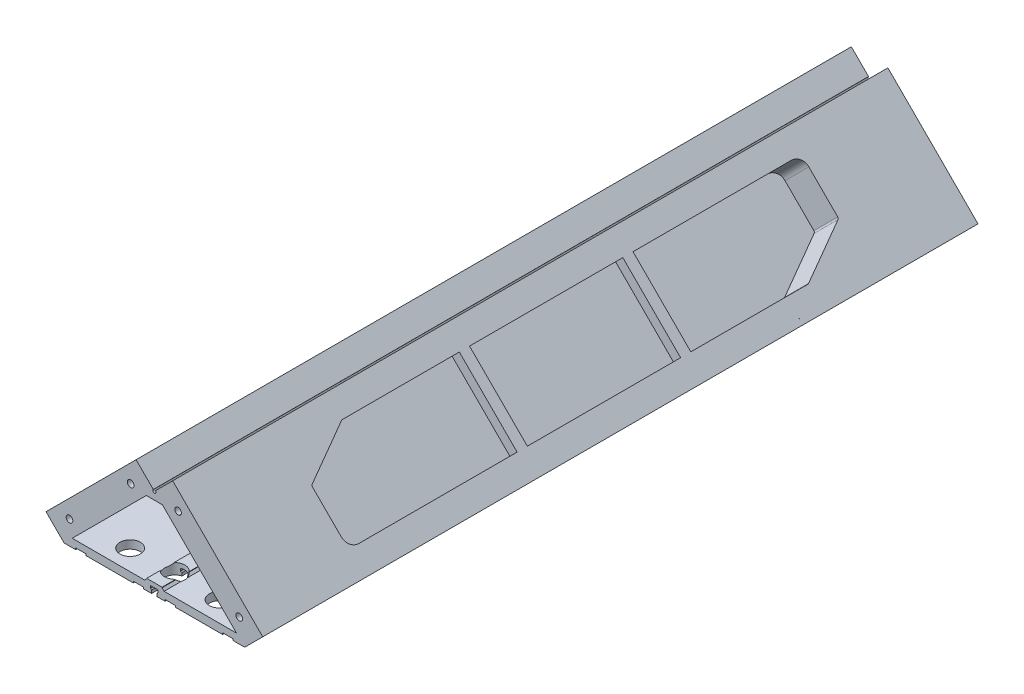
from build123d import *

# Parameters (mm, degrees)
SKETCH1_W            = 540
SKETCH1_H            = 840
BOSS_EXTRUDE1_DEPTH  = 25
SKETCH2_W            = 25
SKETCH2_H            = 25
SKETCH2_W_2          = 21
SKETCH2_H_2          = 21
BOSS_EXTRUDE2_DEPTH  = 700
SKETCH4_W            = 540
SKETCH4_H            = 840
BOSS_EXTRUDE3_DEPTH  = 25
SKETCH6_W            = 4
SKETCH6_H            = 20
BOSS_EXTRUDE4_DEPTH  = 25
SKETCH8_W            = 4
SKETCH8_H            = 20
BOSS_EXTRUDE5_DEPTH  = 25
BOSS_EXTRUDE6_DEPTH  = 750
SKETCH10_R           = 20
BOSS_EXTRUDE7_DEPTH  = 6
SKETCH11_W           = 28
SKETCH11_H           = 45
BOSS_EXTRUDE8_DEPTH  = 2
SKETCH12_W           = 2
SKETCH12_H           = 45
BOSS_EXTRUDE9_DEPTH  = 38
CUT_EXTRUDE1_DEPTH   = 633.198416853
FILLET1_R            = 6
SKETCH14_R           = 25
BOSS_EXTRUDE10_DEPTH = 24
SKETCH15_R           = 25
BOSS_EXTRUDE11_DEPTH = 24
BOSS_EXTRUDE13_DEPTH = 700
SKETCH19_OUTSIDE_W   = 1016.89
SKETCH19_OUTSIDE_H   = 1690.493
CUT_EXTRUDE2_DEPTH   = 789.020646546
SKETCH20_R           = 150.366879017
CUT_EXTRUDE3_DEPTH   = 25
SKETCH21_R           = 126.600739992
CUT_EXTRUDE4_DEPTH   = 25
SKETCH22_R           = 452.219226755
CUT_EXTRUDE5_DEPTH   = 39.020646546
SKETCH25_W           = 10.2
SKETCH25_H           = 3
CUT_EXTRUDE7_DEPTH   = 701
CUT_EXTRUDE8_DEPTH   = 701
SKETCH32_W           = 15
SKETCH32_H           = 2.5
BOSS_EXTRUDE15_DEPTH = 700
CHAMFER1_SIZE        = 2
CHAMFER2_SIZE        = 2
BOSS_EXTRUDE16_DEPTH = 700
CUT_EXTRUDE12_DEPTH  = 6
BOSS_EXTRUDE17_DEPTH = 33
BOSS_EXTRUDE18_DEPTH = 4
FILLET2_R            = 2
CUT_EXTRUDE13_DEPTH  = 10
BOSS_EXTRUDE19_DEPTH = 33
BOSS_EXTRUDE20_DEPTH = 4
BOSS_EXTRUDE21_DEPTH = 10
BOSS_EXTRUDE22_DEPTH = 10
SKETCH48_R           = 10
CUT_EXTRUDE14_DEPTH  = 20
SKETCH49_W           = 350
SKETCH49_H           = 5
CUT_EXTRUDE15_DEPTH  = 10
FILLET3_R            = 2
SKETCH50_W           = 350
SKETCH50_H           = 5
CUT_EXTRUDE16_DEPTH  = 10
FILLET4_R            = 2
SKETCH51_W           = 10
SKETCH51_H           = 80
BOSS_EXTRUDE23_DEPTH = 10
SKETCH53_W           = 10
SKETCH53_H           = 80
BOSS_EXTRUDE24_DEPTH = 10
BOSS_EXTRUDE25_DEPTH = 15
BOSS_EXTRUDE26_DEPTH = 15
SKETCH57_R           = 3.25
CUT_EXTRUDE17_DEPTH  = 20
SKETCH58_R           = 3.25
CUT_EXTRUDE18_DEPTH  = 20


with BuildPart() as part:
    # Sketch1 → Boss-Extrude1 (new body)
    with BuildSketch(Plane.XY):
        Polygon((565, 0), (590, 0), (590, 950), (613.198051534, 926.801948466), (630.875721064, 944.479617996), (312.67766953, 1262.67766953), (295, 1280.355339059), (277.32233047, 1262.67766953), (-40.875721064, 944.479617996), (-23.198051534, 926.801948466), (0, 950), (0, 0), (25, 0), (25, 30), (565, 30), align=None)
        with Locations((295, 475)):
            Rectangle(SKETCH1_W, SKETCH1_H, mode=Mode.SUBTRACT)
        Polygon((25, 920), (565, 920), (565, 950), (565, 975), (295, 1245), (25, 975), (25, 950), align=None, mode=Mode.SUBTRACT)
    extrude(amount=BOSS_EXTRUDE1_DEPTH)

    # Sketch2 → Boss-Extrude2 (add)
    with BuildSketch(Plane.XY.offset(25)):
        with Locations((12.5, 42.5)):
            Rectangle(SKETCH2_W, SKETCH2_H)
        with Locations((12.5, 42.5)):
            Rectangle(SKETCH2_W_2, SKETCH2_H_2, mode=Mode.SUBTRACT)
        with Locations((577.5, 42.5)):
            Rectangle(SKETCH2_W, SKETCH2_H)
        with Locations((577.5, 42.5)):
            Rectangle(SKETCH2_W_2, SKETCH2_H_2, mode=Mode.SUBTRACT)
        Polygon((295, 1280.355339059), (312.67766953, 1262.67766953), (295, 1245), (277.32233047, 1262.67766953), align=None)
        Polygon((295, 1277.526911935), (309.849242405, 1262.67766953), (295, 1247.828427125), (280.150757595, 1262.67766953), align=None, mode=Mode.SUBTRACT)
        with Locations((12.5, 907.5)):
            Rectangle(SKETCH2_W, SKETCH2_H)
        with Locations((12.5, 907.5)):
            Rectangle(SKETCH2_W_2, SKETCH2_H_2, mode=Mode.SUBTRACT)
        with Locations((577.5, 907.5)):
            Rectangle(SKETCH2_W, SKETCH2_H)
        with Locations((577.5, 907.5)):
            Rectangle(SKETCH2_W_2, SKETCH2_H_2, mode=Mode.SUBTRACT)
    extrude(amount=BOSS_EXTRUDE2_DEPTH)

    # Sketch4 → Boss-Extrude3 (add)
    with BuildSketch(Plane.XY.offset(725)):
        Polygon((590, 895), (590, 920), (590, 950), (613.198051534, 926.801948466), (630.875721064, 944.479617996), (312.67766953, 1262.67766953), (295, 1280.355339059), (277.32233047, 1262.67766953), (-40.875721064, 944.479617996), (-23.198051534, 926.801948466), (0, 950), (0, 920), (0, 895), (0, 55), (0, 30), (0, 0), (25, 0), (25, 30), (565, 30), (565, 0), (590, 0), (590, 30), (590, 55), align=None)
        with Locations((295, 475)):
            Rectangle(SKETCH4_W, SKETCH4_H, mode=Mode.SUBTRACT)
        Polygon((565, 920), (25, 920), (25, 975), (295, 1245), (565, 975), align=None, mode=Mode.SUBTRACT)
    extrude(amount=BOSS_EXTRUDE3_DEPTH)

    # Sketch6 → Boss-Extrude4 (add)
    with BuildSketch(Plane(origin=(0, 0, 0), x_dir=(-1, 0, 0), z_dir=(0, 0, -1))):
        with Locations((-27, 265)):
            Rectangle(SKETCH6_W, SKETCH6_H)
        with Locations((-27, 665)):
            Rectangle(SKETCH6_W, SKETCH6_H)
        with Locations((-563, 665)):
            Rectangle(SKETCH6_W, SKETCH6_H)
        with Locations((-563, 265)):
            Rectangle(SKETCH6_W, SKETCH6_H)
    extrude(amount=-BOSS_EXTRUDE4_DEPTH)

    # Sketch8 → Boss-Extrude5 (add)
    with BuildSketch(Plane.XY.offset(750)):
        with Locations((27, 665)):
            Rectangle(SKETCH8_W, SKETCH8_H)
        with Locations((27, 265)):
            Rectangle(SKETCH8_W, SKETCH8_H)
        with Locations((563, 265)):
            Rectangle(SKETCH8_W, SKETCH8_H)
        with Locations((563, 665)):
            Rectangle(SKETCH8_W, SKETCH8_H)
    extrude(amount=-BOSS_EXTRUDE5_DEPTH)

    # Sketch9 → Boss-Extrude6 (add)
    with BuildSketch(Plane.XY.offset(750)):
        Polygon((561, 255), (551, 255), (551, 257), (559, 257), (559, 270), (561, 270), align=None)
        Polygon((561, 655), (551, 655), (551, 657), (559, 657), (559, 670), (561, 670), align=None)
        Polygon((31, 670), (31, 657), (39, 657), (39, 655), (29, 655), (29, 670), align=None)
        Polygon((31, 270), (31, 257), (39, 257), (39, 255), (29, 255), (29, 270), align=None)
    extrude(amount=-BOSS_EXTRUDE6_DEPTH)

    # Sketch10 → Boss-Extrude7 (add)
    with BuildSketch(Plane.XZ):
        with Locations((577.5, 12.5)):
            Circle(SKETCH10_R)
        with Locations((577.5, 737.5)):
            Circle(SKETCH10_R)
        with Locations((12.5, 737.5)):
            Circle(SKETCH10_R)
        with Locations((12.5, 12.5)):
            Circle(SKETCH10_R)
    extrude(amount=BOSS_EXTRUDE7_DEPTH)

    # Sketch11 → Boss-Extrude8 (add)
    with BuildSketch(Plane.XZ.offset(6)):
        with Locations((577.32269579, 3.479353454)):
            Rectangle(SKETCH11_W, SKETCH11_H)
        with Locations((577.32269579, 746.520646546)):
            Rectangle(SKETCH11_W, SKETCH11_H)
        with Locations((12.67730421, 746.520646546)):
            Rectangle(SKETCH11_W, SKETCH11_H)
        with Locations((12.67730421, 3.479353454)):
            Rectangle(SKETCH11_W, SKETCH11_H)
    extrude(amount=BOSS_EXTRUDE8_DEPTH)

    # Sketch12 → Boss-Extrude9 (add)
    with BuildSketch(Plane.XZ.offset(8)):
        with Locations((590.32269579, 3.479353454)):
            Rectangle(SKETCH12_W, SKETCH12_H)
        with Locations((564.32269579, 3.479353454)):
            Rectangle(SKETCH12_W, SKETCH12_H)
        with Locations((25.67730421, 3.479353454)):
            Rectangle(SKETCH12_W, SKETCH12_H)
        with Locations((-0.32269579, 3.479353454)):
            Rectangle(SKETCH12_W, SKETCH12_H)
        with Locations((-0.32269579, 746.520646546)):
            Rectangle(SKETCH12_W, SKETCH12_H)
        with Locations((25.67730421, 746.520646546)):
            Rectangle(SKETCH12_W, SKETCH12_H)
        with Locations((564.32269579, 746.520646546)):
            Rectangle(SKETCH12_W, SKETCH12_H)
        with Locations((590.32269579, 746.520646546)):
            Rectangle(SKETCH12_W, SKETCH12_H)
    extrude(amount=BOSS_EXTRUDE9_DEPTH)

    # Sketch13 → Cut-Extrude1 (cut, through all)
    with BuildSketch(Plane(origin=(591.32269579, 0, 0), x_dir=(0, 0, -1), z_dir=(1, 0, 0))):
        Polygon((-25.979353454, -6), (9.020646546, -46), (-32.88674387, -57.116728835), align=None)
        Polygon((-717.11325613, -57.116728835), (-724.020646546, -6), (-759.020646546, -46), align=None)
    extrude(amount=-CUT_EXTRUDE1_DEPTH, mode=Mode.SUBTRACT)

    # Fillet1
    fillet1_edges = [part.edges().sort_by_distance(p)[0] for p in [
        (590.32269579, -46, -19.020646546),
        (564.32269579, -46, -19.020646546),
        (25.67730421, -46, -19.020646546),
        (-0.32269579, -46, -19.020646546),
        (-0.32269579, -46, 769.020646546),
        (25.67730421, -46, 769.020646546),
        (564.32269579, -46, 769.020646546),
        (590.32269579, -46, 769.020646546),
        (590.32269579, -46, 759.020646546),
        (-0.32269579, -46, -9.020646546),
        (25.67730421, -46, -9.020646546),
        (564.32269579, -46, -9.020646546),
        (590.32269579, -46, -9.020646546),
        (564.32269579, -46, 759.020646546),
        (-0.32269579, -46, 759.020646546),
        (25.67730421, -46, 759.020646546),
    ]]
    fillet(fillet1_edges, radius=FILLET1_R)

    # Sketch14 → Boss-Extrude10 (add)
    with BuildSketch(Plane(origin=(565.32269579, 0, 0), x_dir=(0, 0, -1), z_dir=(1, 0, 0))):
        with Locations((13.020646546, -40)):
            Circle(SKETCH14_R)
        with Locations((-763.020646546, -40)):
            Circle(SKETCH14_R)
    extrude(amount=BOSS_EXTRUDE10_DEPTH)

    # Sketch15 → Boss-Extrude11 (add)
    with BuildSketch(Plane.ZY.offset(-24.67730421)):
        with Locations((763.020646546, -40)):
            Circle(SKETCH15_R)
        with Locations((-13.020646546, -40)):
            Circle(SKETCH15_R)
    extrude(amount=BOSS_EXTRUDE11_DEPTH)

    # Sketch18 → Boss-Extrude13 (add)
    with BuildSketch(Plane.XY.offset(25)):
        with BuildLine():
            Line((277.110198436, 1262.465537495), (188.933982822, 1174.289321881))
            Line((188.933982822, 1174.289321881), (206.611652352, 1156.611652352))
            Line((206.611652352, 1156.611652352), (383.388347648, 1156.611652352))
            Line((383.388347648, 1156.611652352), (401.066017178, 1174.289321881))
            Line((401.066017178, 1174.289321881), (312.889801564, 1262.465537495))
            Line((312.889801564, 1262.465537495), (296.060660172, 1245.636396103))
            ThreePointArc((296.060660172, 1245.636396103), (295, 1243.075735931), (293.939339828, 1245.636396103))
            Line((293.939339828, 1245.636396103), (277.110198436, 1262.465537495))
        make_face()
        Polygon((277.110198436, 1255.394469683), (196.005050634, 1174.289321881), (205.682720164, 1164.611652352), (384.317279836, 1164.611652352), (393.994949366, 1174.289321881), (312.889801564, 1255.394469683), (295, 1237.504668119), align=None, mode=Mode.SUBTRACT)
    extrude(amount=BOSS_EXTRUDE13_DEPTH)

    # Sketch19 outside → Cut-Extrude2 (cut, through all)
    with BuildSketch(Plane(origin=(0, 0, 0), x_dir=(-1, 0, 0), z_dir=(0, 0, -1))):
        with Locations((-295, 607.6775)):
            Rectangle(SKETCH19_OUTSIDE_W, SKETCH19_OUTSIDE_H)
        with BuildLine():
            Line((-401.066017178, 1174.289321881), (-312.889801564, 1262.465537495))
            Line((-312.889801564, 1262.465537495), (-296.060660172, 1245.636396103))
            ThreePointArc((-296.060660172, 1245.636396103), (-295, 1243.075735931), (-293.939339828, 1245.636396103))
            Line((-293.939339828, 1245.636396103), (-277.110198436, 1262.465537495))
            Line((-277.110198436, 1262.465537495), (-188.933982822, 1174.289321881))
            Line((-188.933982822, 1174.289321881), (-206.611652352, 1156.611652352))
            Line((-206.611652352, 1156.611652352), (-383.388347648, 1156.611652352))
            Line((-383.388347648, 1156.611652352), (-401.066017178, 1174.289321881))
        make_face(mode=Mode.SUBTRACT)
    extrude(amount=-CUT_EXTRUDE2_DEPTH, mode=Mode.SUBTRACT)

    # Sketch20 → Cut-Extrude3 (cut)
    with BuildSketch(Plane(origin=(0, 0, 0), x_dir=(-1, 0, 0), z_dir=(0, 0, -1))):
        with Locations((-293.022121053, 1200.600764851)):
            Circle(SKETCH20_R)
    extrude(amount=-CUT_EXTRUDE3_DEPTH, mode=Mode.SUBTRACT)

    # Sketch21 → Cut-Extrude4 (cut)
    with BuildSketch(Plane.XY.offset(750)):
        with Locations((288.084440034, 1190.288136264)):
            Circle(SKETCH21_R)
    extrude(amount=-CUT_EXTRUDE4_DEPTH, mode=Mode.SUBTRACT)

    # Sketch22 → Cut-Extrude5 (cut, through all)
    with BuildSketch(Plane.XY):
        with Locations((322.401617547, 0)):
            Circle(SKETCH22_R)
    extrude(amount=-CUT_EXTRUDE5_DEPTH, mode=Mode.SUBTRACT)

    # Sketch25 → Cut-Extrude7 (cut, through all)
    with BuildSketch(Plane(origin=(0, 0, 25), x_dir=(-1, 0, 0), z_dir=(0, 0, -1))):
        with Locations((-366.883174851, 1156.611652352)):
            Rectangle(SKETCH25_W, SKETCH25_H)
        with Locations((-310.559598677, 1156.611652352)):
            Rectangle(SKETCH25_W, SKETCH25_H)
        with Locations((-279.440401323, 1156.611652352)):
            Rectangle(SKETCH25_W, SKETCH25_H)
        with Locations((-223.116825149, 1156.611652352)):
            Rectangle(SKETCH25_W, SKETCH25_H)
    extrude(amount=-CUT_EXTRUDE7_DEPTH, mode=Mode.SUBTRACT)

    # Sketch28 → Cut-Extrude8 (cut, through all)
    with BuildSketch(Plane(origin=(0, 0, 25), x_dir=(-1, 0, 0), z_dir=(0, 0, -1))):
        Polygon((-297.7, 1153.411652352), (-292.3, 1153.411652352), (-292.3, 1159.528809639), (-291.3, 1160.528809639), (-291.3, 1162.811652352), (-298.7, 1162.811652352), (-298.7, 1160.528809639), (-297.7, 1159.528809639), align=None)
    extrude(amount=-CUT_EXTRUDE8_DEPTH, mode=Mode.SUBTRACT)

    # Sketch32 → Boss-Extrude15 (add)
    with BuildSketch(Plane(origin=(0, 0, 25), x_dir=(-1, 0, 0), z_dir=(0, 0, -1))):
        with Locations((-295, 1165.861652352)):
            Rectangle(SKETCH32_W, SKETCH32_H)
    extrude(amount=-BOSS_EXTRUDE15_DEPTH)

    # Chamfer1
    chamfer1_edges = [part.edges().sort_by_distance(p)[0] for p in [
        (302.5, 1164.611652352, 375),
    ]]
    chamfer(chamfer1_edges, length=CHAMFER1_SIZE)

    # Chamfer2
    chamfer2_edges = [part.edges().sort_by_distance(p)[0] for p in [
        (287.5, 1164.611652352, 375),
    ]]
    chamfer(chamfer2_edges, length=CHAMFER2_SIZE)

    # Sketch36 → Boss-Extrude16 (add)
    with BuildSketch(Plane(origin=(0, 0, 25), x_dir=(-1, 0, 0), z_dir=(0, 0, -1))):
        with BuildLine():
            Line((-291.204031039, 1245.108659773), (-287.5, 1245.108659773))
            Line((-287.5, 1245.108659773), (-287.5, 1237.108659773))
            Line((-287.5, 1237.108659773), (-302.5, 1237.108659773))
            Line((-302.5, 1237.108659773), (-302.5, 1245.108659773))
            Line((-302.5, 1245.108659773), (-298.795968961, 1245.108659773))
            ThreePointArc((-298.795968961, 1245.108659773), (-295, 1240.742540375), (-291.204031039, 1245.108659773))
        make_face()
    extrude(amount=-BOSS_EXTRUDE16_DEPTH)

    # Sketch38 → Cut-Extrude12 (cut)
    with BuildSketch(Plane(origin=(787.67766953, 787.67766953, 0), x_dir=(0, 0, -1), z_dir=(0.707106781, 0.707106781, 0))):
        with BuildLine():
            Line((-575, 649.451442127), (-135, 649.451442127))
            ThreePointArc((-135, 649.451442127), (-127.928932188, 646.522509939), (-125, 639.451442127))
            Line((-125, 639.451442127), (-125, 598.318955587))
            Line((-125, 598.318955587), (-175, 569.451442127))
            Line((-175, 569.451442127), (-615, 569.451442127))
            ThreePointArc((-615, 569.451442127), (-622.071067812, 572.380374315), (-625, 579.451442127))
            Line((-625, 579.451442127), (-625, 620.583928668))
            Line((-625, 620.583928668), (-575, 649.451442127))
        make_face()
    extrude(amount=-CUT_EXTRUDE12_DEPTH, mode=Mode.SUBTRACT)

    # Sketch39 → Boss-Extrude17 (add)
    with BuildSketch(Plane(origin=(787.67766953, 787.67766953, 0), x_dir=(0, 0, -1), z_dir=(0.707106781, 0.707106781, 0))):
        with BuildLine():
            Line((-121, 596.00955451), (-121, 639.451442127))
            ThreePointArc((-121, 639.451442127), (-125.100505063, 649.350937064), (-135, 653.451442127))
            Line((-135, 653.451442127), (-576.07179677, 653.451442127))
            Line((-576.07179677, 653.451442127), (-629, 622.893329745))
            Line((-629, 622.893329745), (-629, 579.451442127))
            ThreePointArc((-629, 579.451442127), (-624.899494937, 569.551947191), (-615, 565.451442127))
            Line((-615, 565.451442127), (-173.92820323, 565.451442127))
            Line((-173.92820323, 565.451442127), (-121, 596.00955451))
        make_face()
        with BuildLine():
            Line((-125, 598.318955587), (-125, 639.451442127))
            ThreePointArc((-125, 639.451442127), (-127.928932188, 646.522509939), (-135, 649.451442127))
            Line((-135, 649.451442127), (-575, 649.451442127))
            Line((-575, 649.451442127), (-625, 620.583928668))
            Line((-625, 620.583928668), (-625, 579.451442127))
            ThreePointArc((-625, 579.451442127), (-622.071067812, 572.380374315), (-615, 569.451442127))
            Line((-615, 569.451442127), (-175, 569.451442127))
            Line((-175, 569.451442127), (-125, 598.318955587))
        make_face(mode=Mode.SUBTRACT)
    extrude(amount=-BOSS_EXTRUDE17_DEPTH)

    # Sketch40 → Boss-Extrude18 (add)
    with BuildSketch(Plane(origin=(764.343145751, 764.34314575, 0), x_dir=(0, 0, 1), z_dir=(-0.707106781, -0.707106781, 0))):
        with BuildLine():
            Line((172.865228929, 566.065150626), (619.099658504, 566.065150626))
            ThreePointArc((619.099658504, 566.065150626), (626.256003266, 571.126636395), (629, 579.451442127))
            Line((629, 579.451442127), (629, 622.893329745))
            Line((629, 622.893329745), (576.07179677, 653.451442127))
            Line((576.07179677, 653.451442127), (135, 653.451442127))
            ThreePointArc((135, 653.451442127), (125.100505063, 649.350937064), (121, 639.451442127))
            Line((121, 639.451442127), (121, 596.00955451))
            Line((121, 596.00955451), (172.865228929, 566.065150626))
        make_face()
    extrude(amount=BOSS_EXTRUDE18_DEPTH)

    # Fillet2
    fillet2_edges = [part.edges().sort_by_distance(p)[0] for p in [
        (352.935016832, 1199.085798448, 125),
        (373.347431355, 1178.673383925, 175),
        (337.191303384, 1214.829511896, 625),
        (316.778888861, 1235.24192642, 575),
    ]]
    fillet(fillet2_edges, radius=FILLET2_R)

    # Sketch42 → Cut-Extrude13 (cut)
    with BuildSketch(Plane(origin=(-492.67766953, 492.67766953, 0), x_dir=(0, 0, 1), z_dir=(-0.707106781, 0.707106781, 0))):
        with BuildLine():
            Line((175, 1066.644443027), (615, 1066.644443027))
            ThreePointArc((615, 1066.644443027), (622.071067812, 1063.715510839), (625, 1056.644443027))
            Line((625, 1056.644443027), (625, 1015.511956487))
            Line((625, 1015.511956487), (575, 986.644443027))
            Line((575, 986.644443027), (135, 986.644443027))
            ThreePointArc((135, 986.644443027), (127.928932188, 989.573375215), (125, 996.644443027))
            Line((125, 996.644443027), (125, 1037.776929568))
            Line((125, 1037.776929568), (175, 1066.644443027))
        make_face()
    extrude(amount=-CUT_EXTRUDE13_DEPTH, mode=Mode.SUBTRACT)

    # Sketch43 → Boss-Extrude19 (add)
    with BuildSketch(Plane(origin=(-492.67766953, 492.67766953, 0), x_dir=(0, 0, 1), z_dir=(-0.707106781, 0.707106781, 0))):
        with BuildLine():
            Line((615, 1070.644443027), (173.92820323, 1070.644443027))
            Line((173.92820323, 1070.644443027), (121, 1040.086330645))
            Line((121, 1040.086330645), (121, 996.644443027))
            ThreePointArc((121, 996.644443027), (125.100505063, 986.744948091), (135, 982.644443027))
            Line((135, 982.644443027), (576.07179677, 982.644443027))
            Line((576.07179677, 982.644443027), (629, 1013.20255541))
            Line((629, 1013.20255541), (629, 1056.644443027))
            ThreePointArc((629, 1056.644443027), (624.899494937, 1066.543937964), (615, 1070.644443027))
        make_face()
        with BuildLine():
            Line((615, 1066.644443027), (175, 1066.644443027))
            Line((175, 1066.644443027), (125, 1037.776929568))
            Line((125, 1037.776929568), (125, 996.644443027))
            ThreePointArc((125, 996.644443027), (127.928932188, 989.573375215), (135, 986.644443027))
            Line((135, 986.644443027), (575, 986.644443027))
            Line((575, 986.644443027), (625, 1015.511956487))
            Line((625, 1015.511956487), (625, 1056.644443027))
            ThreePointArc((625, 1056.644443027), (622.071067812, 1063.715510839), (615, 1066.644443027))
        make_face(mode=Mode.SUBTRACT)
    extrude(amount=-BOSS_EXTRUDE19_DEPTH)

    # Sketch44 → Boss-Extrude20 (add)
    with BuildSketch(Plane(origin=(-469.343145751, 469.343145751, 0), x_dir=(0, 0, -1), z_dir=(0.707106781, -0.707106781, 0))):
        with BuildLine():
            Line((-577.134771071, 983.258151526), (-130.900341496, 983.258151526))
            ThreePointArc((-130.900341496, 983.258151526), (-123.743996734, 988.319637296), (-121, 996.644443027))
            Line((-121, 996.644443027), (-121, 1040.086330645))
            Line((-121, 1040.086330645), (-173.92820323, 1070.644443027))
            Line((-173.92820323, 1070.644443027), (-615, 1070.644443027))
            ThreePointArc((-615, 1070.644443027), (-624.899494937, 1066.543937964), (-629, 1056.644443027))
            Line((-629, 1056.644443027), (-629, 1013.20255541))
            Line((-629, 1013.20255541), (-577.134771071, 983.258151526))
        make_face()
    extrude(amount=BOSS_EXTRUDE20_DEPTH)

    # Sketch46 → Boss-Extrude21 (add)
    with BuildSketch(Plane(origin=(787.67766953, 787.67766953, 0), x_dir=(0, 0, -1), z_dir=(0.707106781, 0.707106781, 0))):
        with BuildLine():
            Line((-135, 659.451442127), (-577.679491924, 659.451442127))
            Line((-577.679491924, 659.451442127), (-635, 626.35743136))
            Line((-635, 626.35743136), (-635, 579.451442127))
            ThreePointArc((-635, 579.451442127), (-629.142135624, 565.309306503), (-615, 559.451442127))
            Line((-615, 559.451442127), (-172.320508076, 559.451442127))
            Line((-172.320508076, 559.451442127), (-115, 592.545452895))
            Line((-115, 592.545452895), (-115, 639.451442127))
            ThreePointArc((-115, 639.451442127), (-120.857864376, 653.593577751), (-135, 659.451442127))
        make_face()
        with BuildLine():
            Line((-135, 649.451442127), (-575, 649.451442127))
            Line((-575, 649.451442127), (-625, 620.583928668))
            Line((-625, 620.583928668), (-625, 579.451442127))
            ThreePointArc((-625, 579.451442127), (-622.071067812, 572.380374315), (-615, 569.451442127))
            Line((-615, 569.451442127), (-175, 569.451442127))
            Line((-175, 569.451442127), (-125, 598.318955587))
            Line((-125, 598.318955587), (-125, 639.451442127))
            ThreePointArc((-125, 639.451442127), (-127.928932188, 646.522509939), (-135, 649.451442127))
        make_face(mode=Mode.SUBTRACT)
    extrude(amount=-BOSS_EXTRUDE21_DEPTH)

    # Sketch47 → Boss-Extrude22 (add)
    with BuildSketch(Plane(origin=(-492.67766953, 492.67766953, 0), x_dir=(0, 0, 1), z_dir=(-0.707106781, 0.707106781, 0))):
        with BuildLine():
            Line((615, 1076.644443027), (172.320508076, 1076.644443027))
            Line((172.320508076, 1076.644443027), (115, 1043.55043226))
            Line((115, 1043.55043226), (115, 996.644443027))
            ThreePointArc((115, 996.644443027), (120.857864376, 982.502307404), (135, 976.644443027))
            Line((135, 976.644443027), (577.679491924, 976.644443027))
            Line((577.679491924, 976.644443027), (635, 1009.738453795))
            Line((635, 1009.738453795), (635, 1056.644443027))
            ThreePointArc((635, 1056.644443027), (629.142135624, 1070.786578651), (615, 1076.644443027))
        make_face()
        with BuildLine():
            Line((615, 1066.644443027), (175, 1066.644443027))
            Line((175, 1066.644443027), (125, 1037.776929568))
            Line((125, 1037.776929568), (125, 996.644443027))
            ThreePointArc((125, 996.644443027), (127.928932188, 989.573375215), (135, 986.644443027))
            Line((135, 986.644443027), (575, 986.644443027))
            Line((575, 986.644443027), (625, 1015.511956487))
            Line((625, 1015.511956487), (625, 1056.644443027))
            ThreePointArc((625, 1056.644443027), (622.071067812, 1063.715510839), (615, 1066.644443027))
        make_face(mode=Mode.SUBTRACT)
    extrude(amount=-BOSS_EXTRUDE22_DEPTH)

    # Sketch48 → Cut-Extrude14 (cut)
    with BuildSketch(Plane.XZ.offset(-1156.611652352)):
        with Locations((295, 705)):
            Circle(SKETCH48_R)
        with Locations((338.72, 705)):
            Circle(SKETCH48_R)
        with Locations((251.278613236, 705)):
            Circle(SKETCH48_R)
        with Locations((251.278613236, 45)):
            Circle(SKETCH48_R)
        with Locations((338.72, 45)):
            Circle(SKETCH48_R)
        with Locations((295, 45)):
            Circle(SKETCH48_R)
    extrude(amount=-CUT_EXTRUDE14_DEPTH, mode=Mode.SUBTRACT)

    # Sketch49 → Cut-Extrude15 (cut)
    with BuildSketch(Plane(origin=(-459.23151878, 459.23151878, 0), x_dir=(0, 0, -1), z_dir=(0.707106781, -0.707106781, 0))):
        with Locations((-354.732050808, 1083.444443027)):
            Rectangle(SKETCH49_W, SKETCH49_H)
    extrude(amount=-CUT_EXTRUDE15_DEPTH, mode=Mode.SUBTRACT)

    # Fillet3
    fillet3_edges = [part.edges().sort_by_distance(p)[0] for p in [
        (303.697413409, 1224.988878092, 529.732050808),
        (307.232947315, 1228.524411998, 529.732050808),
        (307.232947315, 1228.524411998, 179.732050808),
        (303.697413409, 1224.988878092, 179.732050808),
    ]]
    fillet(fillet3_edges, radius=FILLET3_R)

    # Sketch50 → Cut-Extrude16 (cut)
    with BuildSketch(Plane(origin=(754.23151878, 754.23151878, 0), x_dir=(0, 0, 1), z_dir=(-0.707106781, -0.707106781, 0))):
        with Locations((395, 666.251442127)):
            Rectangle(SKETCH50_W, SKETCH50_H)
    extrude(amount=-CUT_EXTRUDE16_DEPTH, mode=Mode.SUBTRACT)

    # Fillet4
    fillet4_edges = [part.edges().sort_by_distance(p)[0] for p in [
        (286.302586591, 1224.988878092, 220),
        (282.767052685, 1228.524411998, 220),
        (282.767052685, 1228.524411998, 570),
        (286.302586591, 1224.988878092, 570),
    ]]
    fillet(fillet4_edges, radius=FILLET4_R)

    # Sketch51 → Boss-Extrude23 (add)
    with BuildSketch(Plane(origin=(-492.67766953, 492.67766953, 0), x_dir=(0, 0, 1), z_dir=(-0.707106781, 0.707106781, 0))):
        with Locations((295, 1026.644443027)):
            Rectangle(SKETCH51_W, SKETCH51_H)
        with Locations((455, 1026.644443027)):
            Rectangle(SKETCH51_W, SKETCH51_H)
    extrude(amount=-BOSS_EXTRUDE23_DEPTH)

    # Sketch53 → Boss-Extrude24 (add)
    with BuildSketch(Plane(origin=(787.67766953, 787.67766953, 0), x_dir=(0, 0, -1), z_dir=(0.707106781, 0.707106781, 0))):
        with Locations((-455, 609.451442127)):
            Rectangle(SKETCH53_W, SKETCH53_H)
        with Locations((-295, 609.451442127)):
            Rectangle(SKETCH53_W, SKETCH53_H)
    extrude(amount=-BOSS_EXTRUDE24_DEPTH)

    # Sketch55 → Boss-Extrude25 (add)
    with BuildSketch(Plane.XY.offset(725)):
        with BuildLine():
            Line((312.889801564, 1262.465537495), (296.840853616, 1246.416589547))
            ThreePointArc((296.840853616, 1246.416589547), (297.515492185, 1244.787867966), (296.840853616, 1243.159146384))
            Line((296.840853616, 1243.159146384), (383.388347648, 1156.611652352))
            Line((383.388347648, 1156.611652352), (401.066017178, 1174.289321881))
            Line((401.066017178, 1174.289321881), (312.889801564, 1262.465537495))
        make_face()
        with BuildLine():
            Line((188.933982822, 1174.289321881), (277.110198436, 1262.465537495))
            Line((277.110198436, 1262.465537495), (293.159146384, 1246.416589547))
            ThreePointArc((293.159146384, 1246.416589547), (292.484507815, 1244.787867966), (293.159146384, 1243.159146384))
            Line((293.159146384, 1243.159146384), (206.611652352, 1156.611652352))
            Line((206.611652352, 1156.611652352), (188.933982822, 1174.289321881))
        make_face()
    extrude(amount=-BOSS_EXTRUDE25_DEPTH)

    # Sketch56 → Boss-Extrude26 (add)
    with BuildSketch(Plane(origin=(0, 0, 25), x_dir=(-1, 0, 0), z_dir=(0, 0, -1))):
        with BuildLine():
            Line((-312.889801564, 1262.465537495), (-296.83386156, 1246.409597491))
            ThreePointArc((-296.83386156, 1246.409597491), (-297.505603924, 1244.787867966), (-296.83386156, 1243.16613844))
            Line((-296.83386156, 1243.16613844), (-383.388347648, 1156.611652352))
            Line((-383.388347648, 1156.611652352), (-401.066017178, 1174.289321881))
            Line((-401.066017178, 1174.289321881), (-312.889801564, 1262.465537495))
        make_face()
        with BuildLine():
            Line((-206.611652352, 1156.611652352), (-293.16613844, 1243.16613844))
            ThreePointArc((-293.16613844, 1243.16613844), (-292.494396076, 1244.787867966), (-293.16613844, 1246.409597491))
            Line((-293.16613844, 1246.409597491), (-277.110198436, 1262.465537495))
            Line((-277.110198436, 1262.465537495), (-188.933982822, 1174.289321881))
            Line((-188.933982822, 1174.289321881), (-206.611652352, 1156.611652352))
        make_face()
    extrude(amount=-BOSS_EXTRUDE26_DEPTH)

    # Sketch57 → Cut-Extrude17 (cut)
    with BuildSketch(Plane(origin=(0, 0, 25), x_dir=(-1, 0, 0), z_dir=(0, 0, -1))):
        with Locations((-318.193102423, 1239.484567107)):
            Circle(SKETCH57_R)
        with Locations((-378.085046789, 1179.59262274)):
            Circle(SKETCH57_R)
        with Locations((-211.914953211, 1179.59262274)):
            Circle(SKETCH57_R)
        with Locations((-271.806897577, 1239.484567107)):
            Circle(SKETCH57_R)
    extrude(amount=-CUT_EXTRUDE17_DEPTH, mode=Mode.SUBTRACT)

    # Sketch58 → Cut-Extrude18 (cut)
    with BuildSketch(Plane.XY.offset(725)):
        with Locations((318.193102423, 1239.484567107)):
            Circle(SKETCH58_R)
        with Locations((378.085046789, 1179.59262274)):
            Circle(SKETCH58_R)
        with Locations((211.914953211, 1179.59262274)):
            Circle(SKETCH58_R)
        with Locations((271.806897577, 1239.484567107)):
            Circle(SKETCH58_R)
    extrude(amount=-CUT_EXTRUDE18_DEPTH, mode=Mode.SUBTRACT)


solid = part.part
